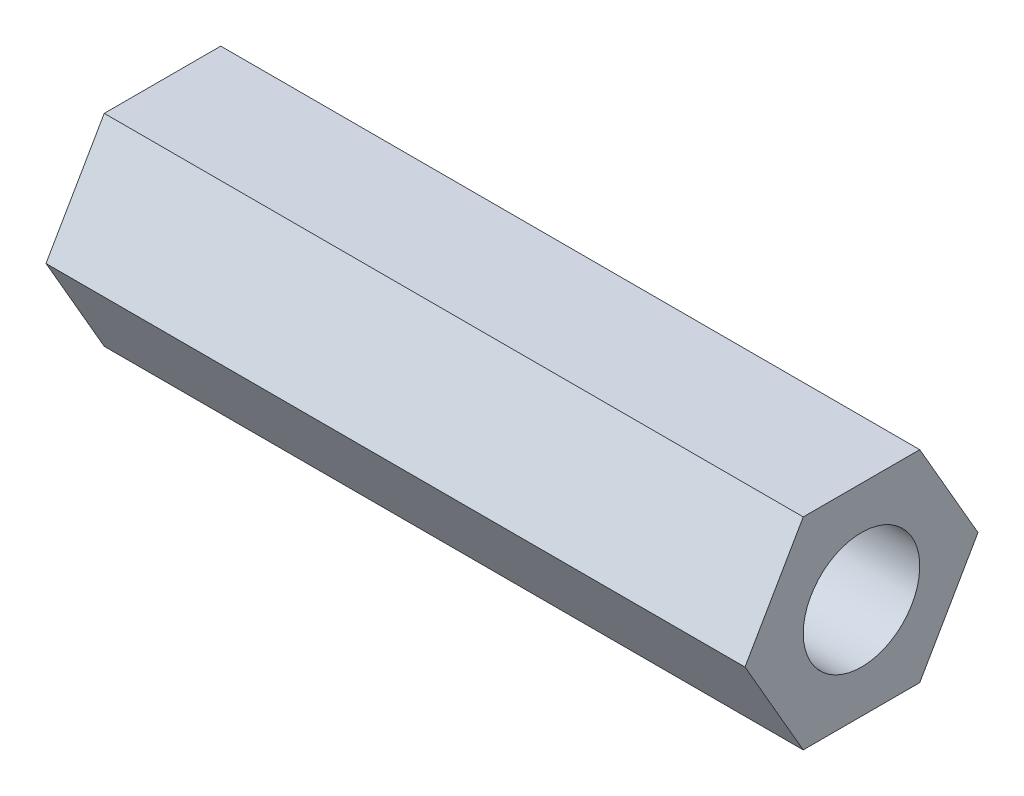
from build123d import *

# Parameters (mm, degrees)
BOSS_EXTRUDE1_DEPTH = 38.1
SKETCH2_R           = 3.175
CUT_EXTRUDE1_DEPTH  = 39.1


with BuildPart() as part:
    # Sketch1 → Boss-Extrude1 (new body)
    with BuildSketch(Plane(origin=(0, 0, 0), x_dir=(0, 0, -1), z_dir=(1, 0, 0))):
        Polygon((6.35, -1.3864e-05), (3.175012007, 5.499254382), (-3.174987993, 5.499268246), (-6.35, 1.3864e-05), (-3.175012007, -5.499254382), (3.174987993, -5.499268246), align=None)
    extrude(amount=BOSS_EXTRUDE1_DEPTH)

    # Sketch2 → Cut-Extrude1 (cut, through all)
    with BuildSketch(Plane.ZY):
        Circle(SKETCH2_R)
    extrude(amount=-CUT_EXTRUDE1_DEPTH, mode=Mode.SUBTRACT)


solid = part.part
